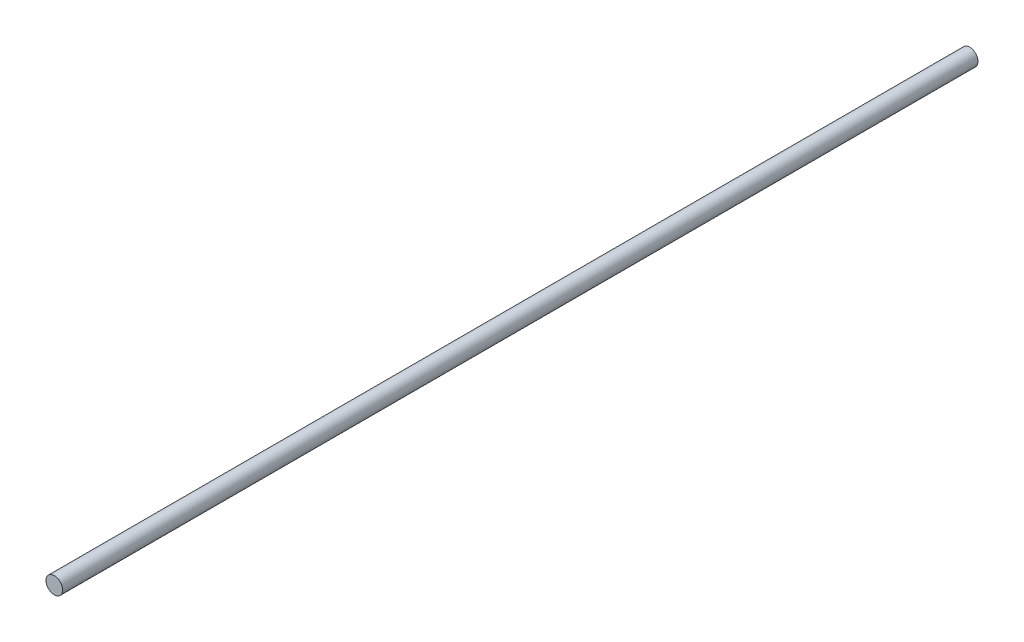
from build123d import *

# Parameters (mm, degrees)
SKETCH1_R           = 10
BOSS_EXTRUDE1_DEPTH = 1100


with BuildPart() as part:
    # Sketch1 → Boss-Extrude1 (new body)
    with BuildSketch(Plane.XY):
        Circle(SKETCH1_R)
    extrude(amount=BOSS_EXTRUDE1_DEPTH)


solid = part.part
